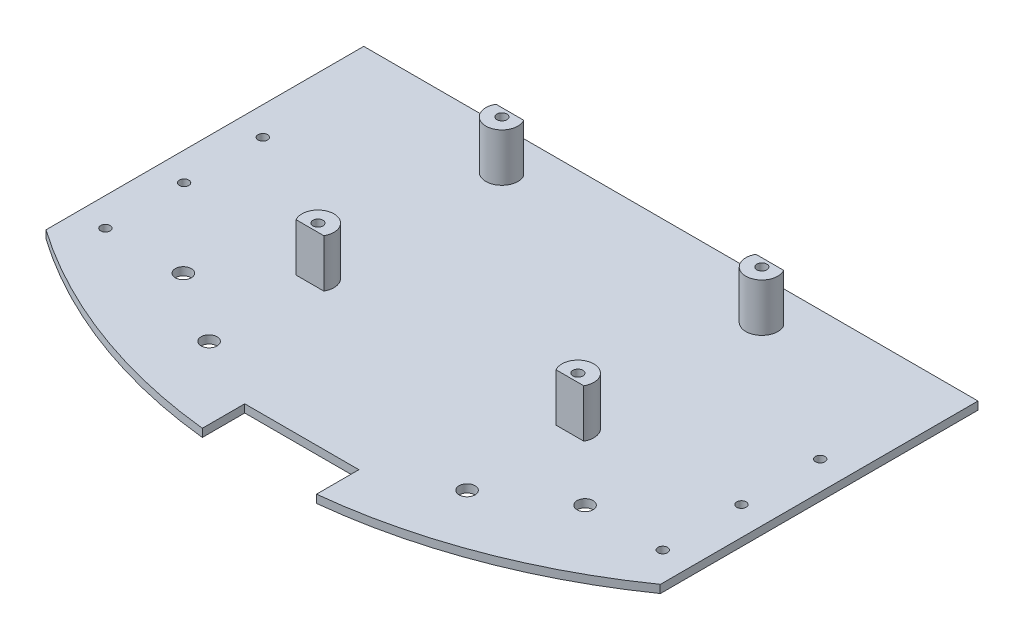
from build123d import *

# Parameters (mm, degrees)
SKETCH1_W           = 195.072
SKETCH1_H           = 152.4
BOSS_EXTRUDE1_DEPTH = 2.54
SKETCH2_R           = 1.5875
SKETCH2_R_2         = 1.5
SKETCH2_R_3         = 2.54
SKETCH2_W           = 36.254936194
SKETCH2_H           = 46.345137013
CUT_EXTRUDE1_DEPTH  = 2.54
CUT_EXTRUDE2_DEPTH  = 2.54
SKETCH6_R           = 1.5875
BOSS_EXTRUDE2_DEPTH = 15.24


with BuildPart() as part:
    # Sketch1 → Boss-Extrude1 (new body)
    with BuildSketch(Plane(origin=(0, 0, 0), x_dir=(1, 0, 0), z_dir=(0, 1, 0))):
        with Locations((97.536, 76.2)):
            Rectangle(SKETCH1_W, SKETCH1_H)
    extrude(amount=BOSS_EXTRUDE1_DEPTH)

    # Sketch2 → Cut-Extrude1 (cut)
    with BuildSketch(Plane(origin=(0, 2.54, 0), x_dir=(1, 0, 0), z_dir=(0, 1, 0))):
        with Locations((56.571242474, 139.7)):
            Circle(SKETCH2_R)
        with Locations((139.121242474, 139.7)):
            Circle(SKETCH2_R)
        with Locations((139.121242474, 81.28)):
            Circle(SKETCH2_R)
        with Locations((56.571242474, 81.28)):
            Circle(SKETCH2_R)
        with Locations((186, 61.35)):
            Circle(SKETCH2_R_2)
        with Locations((186, 86.35)):
            Circle(SKETCH2_R_2)
        with Locations((186, 111.35)):
            Circle(SKETCH2_R_2)
        with Locations((9, 111.35)):
            Circle(SKETCH2_R_2)
        with Locations((9, 86.35)):
            Circle(SKETCH2_R_2)
        with Locations((9, 61.35)):
            Circle(SKETCH2_R_2)
        with Locations((56.571242474, 46.705739829)):
            Circle(SKETCH2_R_3)
        with Locations((33.737644143, 61.35)):
            Circle(SKETCH2_R_3)
        with Locations((161.334355857, 61.35)):
            Circle(SKETCH2_R_3)
        with Locations((138.500757526, 46.705739829)):
            Circle(SKETCH2_R_3)
        with Locations((97.536, 12.019328057)):
            Rectangle(SKETCH2_W, SKETCH2_H)
    extrude(amount=-CUT_EXTRUDE1_DEPTH, mode=Mode.SUBTRACT)

    # Sketch4 → Cut-Extrude2 (cut)
    with BuildSketch(Plane(origin=(0, 2.54, 0), x_dir=(1, 0, 0), z_dir=(0, 1, 0))):
        with BuildLine():
            Line((195.072, 51.488555228), (195, 51.488555228))
            ThreePointArc((195, 51.488555228), (157.216035085, 31.583435817), (115.663468097, 21.723113302))
            Line((115.663468097, 21.723113302), (115.663468097, 0))
            Line((115.663468097, 0), (195.072, 0))
            Line((195.072, 0), (195.072, 51.488555228))
        make_face()
        with BuildLine():
            ThreePointArc((79.408531903, 21.715391762), (37.817865405, 31.570721166), (0, 51.488555228))
            Line((0, 51.488555228), (0, 0))
            Line((0, 0), (79.408531903, 0))
            Line((79.408531903, 0), (79.408531903, 21.715391762))
        make_face()
    extrude(amount=-CUT_EXTRUDE2_DEPTH, mode=Mode.SUBTRACT)

    # Sketch6 → Boss-Extrude2 (add)
    with BuildSketch(Plane(origin=(0, 2.54, 0), x_dir=(1, 0, 0), z_dir=(0, 1, 0))):
        with BuildLine():
            Line((60.970651525, 142.24), (52.171833423, 142.24))
            ThreePointArc((52.171833423, 142.24), (55.256441725, 134.793096802), (61.651242474, 139.7))
            ThreePointArc((61.651242474, 139.7), (61.478145672, 141.014800749), (60.970651525, 142.24))
        make_face()
        with Locations((56.571242474, 139.7)):
            Circle(SKETCH6_R, mode=Mode.SUBTRACT)
        with BuildLine():
            ThreePointArc((144.201242474, 139.7), (144.028145672, 141.014800749), (143.520651525, 142.24))
            Line((143.520651525, 142.24), (134.721833423, 142.24))
            ThreePointArc((134.721833423, 142.24), (137.806441725, 134.793096802), (144.201242474, 139.7))
        make_face()
        with Locations((139.121242474, 139.7)):
            Circle(SKETCH6_R, mode=Mode.SUBTRACT)
        with BuildLine():
            Line((134.721833423, 78.74), (143.520651525, 78.74))
            ThreePointArc((143.520651525, 78.74), (144.028145672, 79.965199251), (144.201242474, 81.28))
            ThreePointArc((144.201242474, 81.28), (137.806441725, 86.186903198), (134.721833423, 78.74))
        make_face()
        with Locations((139.121242474, 81.28)):
            Circle(SKETCH6_R, mode=Mode.SUBTRACT)
        with BuildLine():
            ThreePointArc((61.651242474, 81.28), (55.256441725, 86.186903198), (52.171833423, 78.74))
            Line((52.171833423, 78.74), (60.970651525, 78.74))
            ThreePointArc((60.970651525, 78.74), (61.478145672, 79.965199251), (61.651242474, 81.28))
        make_face()
        with Locations((56.571242474, 81.28)):
            Circle(SKETCH6_R, mode=Mode.SUBTRACT)
    extrude(amount=BOSS_EXTRUDE2_DEPTH)


solid = part.part
